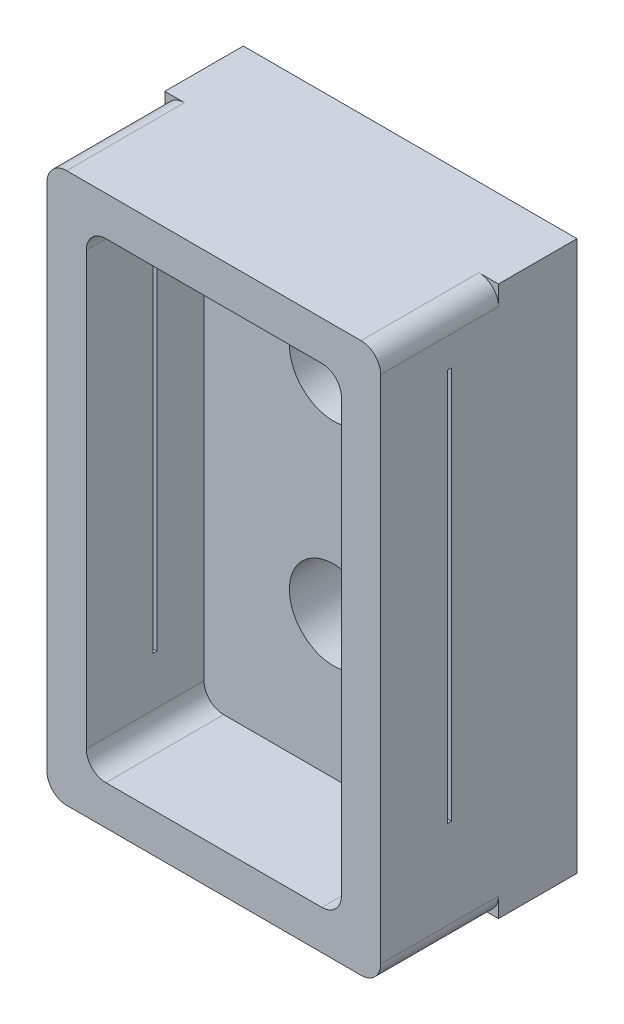
from build123d import *

# Parameters (mm, degrees)
SKETCH1_W               = 21.59
SKETCH1_H               = 35.56
SKETCH1_R               = 2.8575
BOSS_EXTRUDE1_DEPTH     = 12.7
SKETCH2_W               = 16.51
SKETCH2_H               = 30.48
CUT_EXTRUDE1_DEPTH      = 7.62
FILLET1_R               = 1.27
SKETCH3_W               = 0.254
SKETCH3_H               = 25.4
CUT_EXTRUDE3_DEPTH      = 1
CUT_EXTRUDE3_DEPTH_BACK = 22.59
SKETCH1_2_W             = 21.59
SKETCH1_2_H             = 35.56
SKETCH1_2_R             = 2.8575
BOSS_EXTRUDE2_DEPTH     = 5.08


with BuildPart() as part:
    # Sketch1 → Boss-Extrude1 (new body)
    with BuildSketch(Plane.XY):
        with Locations((1.27, -2.511399464)):
            Rectangle(SKETCH1_W, SKETCH1_H)
        with Locations((1.397, 5.108600536)):
            Circle(SKETCH1_R, mode=Mode.SUBTRACT)
        with Locations((1.397, -8.607399464)):
            Circle(SKETCH1_R, mode=Mode.SUBTRACT)
    extrude(amount=BOSS_EXTRUDE1_DEPTH)

    # Sketch2 → Cut-Extrude1 (cut)
    with BuildSketch(Plane.XY.offset(12.7)):
        with Locations((1.27, -2.511399464)):
            Rectangle(SKETCH2_W, SKETCH2_H)
    extrude(amount=-CUT_EXTRUDE1_DEPTH, mode=Mode.SUBTRACT)

    # Fillet1
    fillet1_edges = [part.edges().sort_by_distance(p)[0] for p in [
        (-6.985, -17.751399464, 8.89),
        (-6.985, 12.728600536, 8.89),
        (9.525, 12.728600536, 8.89),
        (9.525, -17.751399464, 8.89),
        (-9.525, 15.268600536, 6.35),
        (12.065, 15.268600536, 6.35),
        (12.065, -20.291399464, 6.35),
        (-9.525, -20.291399464, 6.35),
    ]]
    fillet(fillet1_edges, radius=FILLET1_R)

    # Sketch3 → Cut-Extrude3 (cut, two sides)
    with BuildSketch(Plane(origin=(12.065, 0, 0), x_dir=(0, 0, -1), z_dir=(1, 0, 0))) as cut_extrude3_sk:
        with Locations((-8.255, -0.606399464)):
            Rectangle(SKETCH3_W, SKETCH3_H)
    extrude(amount=CUT_EXTRUDE3_DEPTH, mode=Mode.SUBTRACT)
    extrude(cut_extrude3_sk.sketch, amount=-CUT_EXTRUDE3_DEPTH_BACK, mode=Mode.SUBTRACT)

    # Sketch1_2 → Boss-Extrude2 (add)
    with BuildSketch(Plane.XY):
        with Locations((1.27, -2.511399464)):
            Rectangle(SKETCH1_2_W, SKETCH1_2_H)
        with Locations((1.397, 5.108600536)):
            Circle(SKETCH1_2_R, mode=Mode.SUBTRACT)
        with Locations((1.397, -8.607399464)):
            Circle(SKETCH1_2_R, mode=Mode.SUBTRACT)
    extrude(amount=BOSS_EXTRUDE2_DEPTH)


solid = part.part
